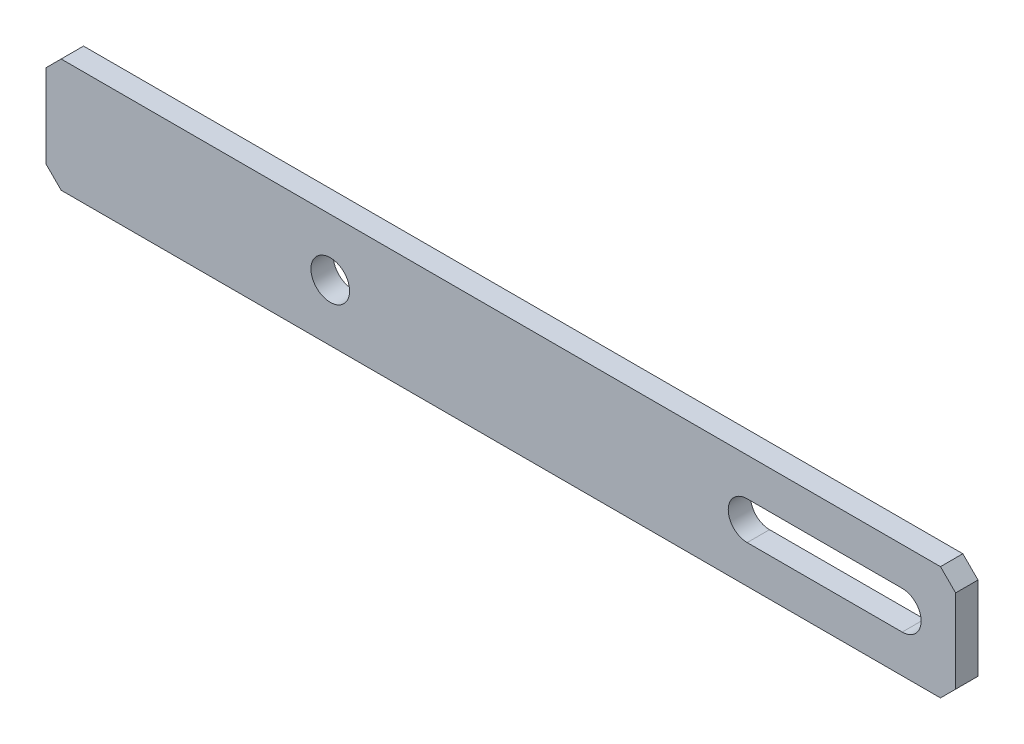
from build123d import *

# Parameters (mm, degrees)
SKETCH1_W           = 120
SKETCH1_H           = 15
SKETCH1_R           = 2.55
BOSS_EXTRUDE1_DEPTH = 2.95
CHAMFER1_SIZE       = 2


with BuildPart() as part:
    # Sketch1 → Boss-Extrude1 (new body)
    with BuildSketch(Plane.XY):
        with Locations((-32.119914347, 29.180942184)):
            Rectangle(SKETCH1_W, SKETCH1_H)
        with Locations((-54.619914347, 29.180942184)):
            Circle(SKETCH1_R, mode=Mode.SUBTRACT)
        with BuildLine():
            Line((0.380085653, 31.680942184), (20.830085653, 31.680942184))
            ThreePointArc((20.830085653, 31.680942184), (23.330085653, 29.180942184), (20.830085653, 26.680942184))
            Line((20.830085653, 26.680942184), (0.380085653, 26.680942184))
            ThreePointArc((0.380085653, 26.680942184), (-2.119914347, 29.180942184), (0.380085653, 31.680942184))
        make_face(mode=Mode.SUBTRACT)
    extrude(amount=BOSS_EXTRUDE1_DEPTH)

    # Chamfer1
    chamfer1_edges = [part.edges().sort_by_distance(p)[0] for p in [
        (27.880085653, 21.680942184, 1.475),
        (-92.119914347, 21.680942184, 1.475),
        (-92.119914347, 36.680942184, 1.475),
        (27.880085653, 36.680942184, 1.475),
    ]]
    chamfer(chamfer1_edges, length=CHAMFER1_SIZE)


solid = part.part
